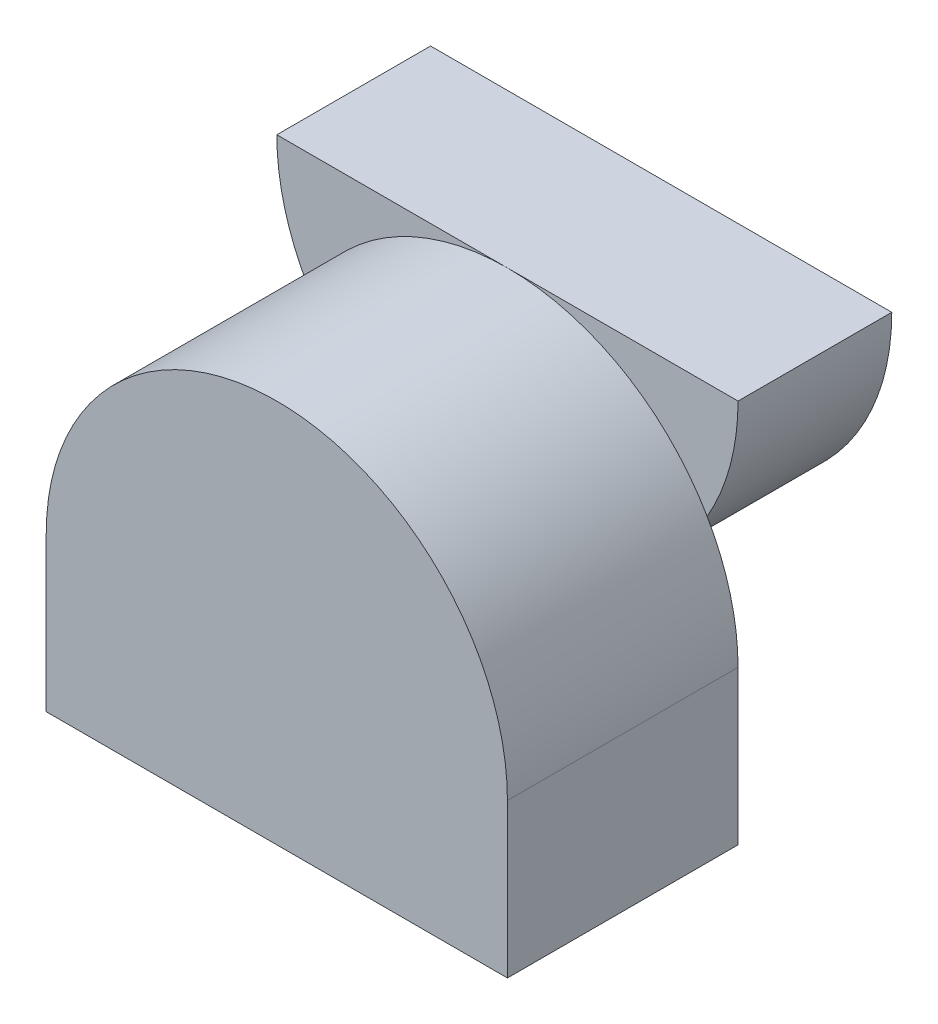
from build123d import *

# Parameters (mm, degrees)
BOSS_EXTRUDE2_DEPTH = 15
BOSS_EXTRUDE3_DEPTH = 10


with BuildPart() as part:
    # Sketch1 → Boss-Extrude2 (new body)
    with BuildSketch(Plane.XY):
        with BuildLine():
            Line((-30, 10), (-30, 0))
            Line((-30, 0), (0, 0))
            Line((0, 0), (0, 10))
            ThreePointArc((0, 10), (-15, 25), (-30, 10))
        make_face()
    extrude(amount=BOSS_EXTRUDE2_DEPTH)

    # Sketch2 → Boss-Extrude3 (add)
    with BuildSketch(Plane(origin=(0, 0, 0), x_dir=(-1, 0, 0), z_dir=(0, 0, -1))):
        with BuildLine():
            Line((0, 25), (30, 25))
            ThreePointArc((30, 25), (15, 10), (0, 25))
        make_face()
    extrude(amount=BOSS_EXTRUDE3_DEPTH)


solid = part.part
